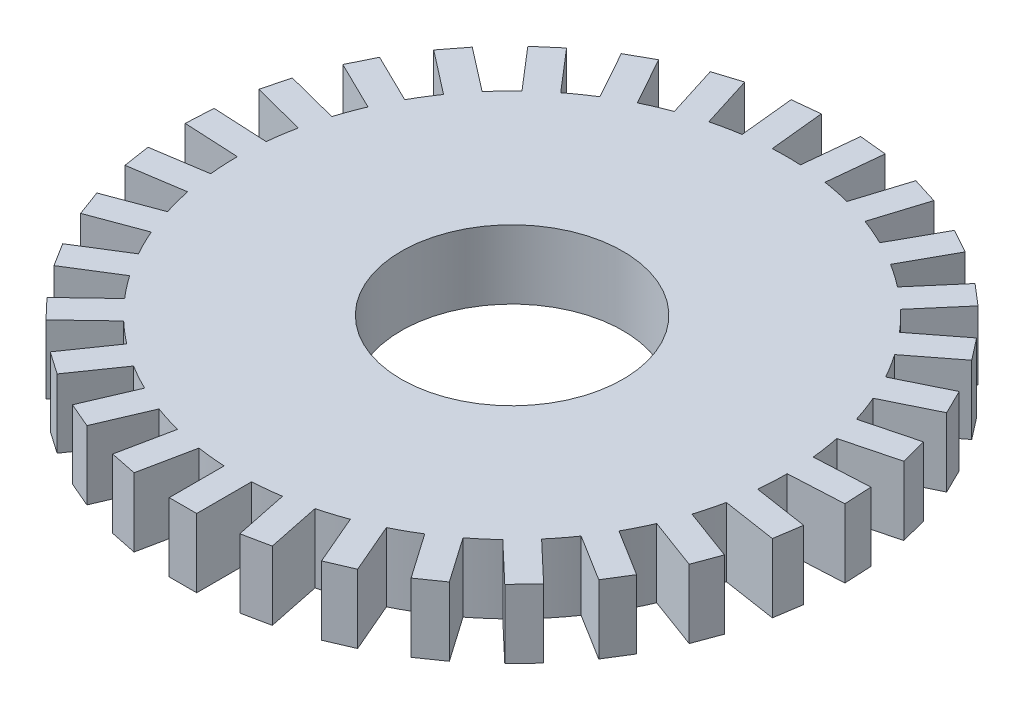
from build123d import *

# Parameters (mm, degrees)
BOSS_EXTRUDE4_DEPTH = 0.635
SKETCH2_R           = 1.00000054
CUT_EXTRUDE1_DEPTH  = 0.635
SKETCH3_R           = 1.025
CUT_EXTRUDE2_DEPTH  = 10


with BuildPart() as part:
    # Sketch1 → Boss-Extrude4 (new body)
    with BuildSketch(Plane(origin=(0, 0, 0), x_dir=(1, 0, 0), z_dir=(0, 1, 0))):
        with BuildLine():
            ThreePointArc((-0.384566693, 2.510718714), (-0.512856006, 2.487685414), (-0.63979484, 2.458101414))
            Line((-0.63979484, 2.458101414), (-0.882098552, 2.381911448))
            ThreePointArc((-0.882098552, 2.381911448), (-1.003125205, 2.333525192), (-1.121510378, 2.27899418))
            ThreePointArc((-1.121510378, 2.27899418), (-1.234057322, 2.220068135), (-1.343517192, 2.155588447))
            ThreePointArc((-1.343517192, 2.155588447), (-1.452326341, 2.083830175), (-1.557311151, 2.006584655))
            ThreePointArc((-1.557311151, 2.006584655), (-1.655692526, 1.926209297), (-1.749932081, 1.841015403))
            ThreePointArc((-1.749932081, 1.841015403), (-1.842069066, 1.748822906), (-1.929355422, 1.65202532))
            ThreePointArc((-1.929355422, 1.65202532), (-2.009543484, 1.553491225), (-2.084704544, 1.451070971))
            ThreePointArc((-2.084704544, 1.451070971), (-2.156397267, 1.342218621), (-2.222411655, 1.229831873))
            ThreePointArc((-2.222411655, 1.229831873), (-2.281123495, 1.117173039), (-2.334128959, 1.001719524))
            ThreePointArc((-2.334128959, 1.001719524), (-2.38244231, 0.880663749), (-2.424482094, 0.757288965))
            ThreePointArc((-2.424482094, 0.757288965), (-2.459314043, 0.635117657), (-2.487993859, 0.511357561))
            ThreePointArc((-2.487993859, 0.511357561), (-2.510949886, 0.383054399), (-2.527293951, 0.253742558))
            ThreePointArc((-2.527293951, 0.253742558), (-2.536819984, 0.127060484), (-2.539999999, 6.056e-05))
            ThreePointArc((-2.539999999, 6.056e-05), (-2.536658877, -0.130237243), (-2.526638097, -0.260192099))
            ThreePointArc((-2.526638097, -0.260192099), (-2.510468218, -0.38619856), (-2.488018241, -0.511238921))
            ThreePointArc((-2.488018241, -0.511238921), (-2.458516757, -0.638196957), (-2.422541382, -0.763474461))
            ThreePointArc((-2.422541382, -0.763474461), (-2.381337587, -0.88364659), (-2.334176723, -1.00160822))
            ThreePointArc((-2.334176723, -1.00160822), (-2.279722671, -1.120028813), (-2.219265538, -1.235500089))
            ThreePointArc((-2.219265538, -1.235500089), (-2.154714716, -1.344918024), (-2.084773736, -1.450971561))
            ThreePointArc((-2.084773736, -1.450971561), (-2.007596472, -1.556006557), (-1.925132703, -1.656944198))
            ThreePointArc((-1.925132703, -1.656944198), (-1.839877571, -1.751128357), (-1.750019867, -1.840931955))
            ThreePointArc((-1.750019867, -1.840931955), (-1.653279037, -1.92828121), (-1.552184709, -2.010552817))
            ThreePointArc((-1.552184709, -2.010552817), (-1.449715623, -2.085647289), (-1.34361998, -2.155524379))
            ThreePointArc((-1.34361998, -2.155524379), (-1.231276164, -2.221611804), (-1.11569009, -2.281849168))
            ThreePointArc((-1.11569009, -2.281849168), (-1.000202146, -2.334779576), (-0.882212132, -2.381869382))
            ThreePointArc((-0.882212132, -2.381869382), (-0.7588647, -2.42398935), (-0.633518988, -2.459726345))
            ThreePointArc((-0.633518988, -2.459726345), (-0.509740276, -2.488325712), (-0.384686416, -2.510700373))
            ThreePointArc((-0.384686416, -2.510700373), (-0.255385227, -2.527128486), (-0.125411544, -2.536902037))
            ThreePointArc((-0.125411544, -2.536902037), (0.001590421, -2.539999502), (0.128588407, -2.536742995))
            ThreePointArc((0.128588407, -2.536742995), (0.258549748, -2.526806686), (0.387830264, -2.510216661))
            ThreePointArc((0.387830264, -2.510216661), (0.512856006, -2.487685414), (0.636598805, -2.458931061))
            ThreePointArc((0.636598805, -2.458931061), (0.761899666, -2.423037123), (0.885194254, -2.380762721))
            ThreePointArc((0.885194254, -2.380762721), (1.003125205, -2.333525192), (1.118546774, -2.2804502))
            ThreePointArc((1.118546774, -2.2804502), (1.234057322, -2.220068135), (1.346318288, -2.153840074))
            ThreePointArc((1.346318288, -2.153840074), (1.452326341, -2.083830175), (1.554701306, -2.00860744))
            ThreePointArc((1.554701306, -2.00860744), (1.655692526, -1.926209297), (1.752323893, -1.838738963))
            ThreePointArc((1.752323893, -1.838738963), (1.842069066, -1.748822906), (1.927206184, -1.654532056))
            ThreePointArc((1.927206184, -1.654532056), (2.009543484, -1.553491225), (2.086589152, -1.448359662))
            ThreePointArc((2.086589152, -1.448359662), (2.156397267, -1.342218621), (2.220811015, -1.232719935))
            ThreePointArc((2.220811015, -1.232719935), (2.281123495, -1.117173039), (2.335429206, -0.998684346))
            ThreePointArc((2.335429206, -0.998684346), (2.38244231, -0.880663749), (2.423495581, -0.760440115))
            ThreePointArc((2.423495581, -0.760440115), (2.459314043, -0.635117657), (2.488656514, -0.508122776))
            ThreePointArc((2.488656514, -0.508122776), (2.510949886, -0.383054399), (2.526961954, -0.257027787))
            ThreePointArc((2.526961954, -0.257027787), (2.536738394, -0.12867913), (2.54, 0))
            ThreePointArc((2.54, 0), (2.539999483, 0.001620701), (2.539997932, 0.003241401))
            ThreePointArc((2.539997932, 0.003241401), (2.536658877, 0.130237243), (2.526974207, 0.256907289))
            ThreePointArc((2.526974207, 0.256907289), (2.510468218, 0.38619856), (2.487351536, 0.514472874))
            ThreePointArc((2.487351536, 0.514472874), (2.458516757, 0.638196957), (2.42353184, 0.76032455))
            ThreePointArc((2.42353184, 0.76032455), (2.381337587, 0.88364659), (2.332872675, 1.004641767))
            ThreePointArc((2.332872675, 1.004641767), (2.279722671, 1.120028813), (2.220869794, 1.232614034))
            ThreePointArc((2.220869794, 1.232614034), (2.154714716, 1.344918024), (2.082885734, 1.453680508))
            ThreePointArc((2.082885734, 1.453680508), (2.007596472, 1.556006557), (1.927285078, 1.654440155))
            ThreePointArc((1.927285078, 1.654440155), (1.839877571, 1.751128357), (1.747625206, 1.843205398))
            ThreePointArc((1.747625206, 1.843205398), (1.653279037, 1.92828121), (1.554797085, 2.008533302))
            ThreePointArc((1.554797085, 2.008533302), (1.449715623, 2.085647289), (1.340816696, 2.157269243))
            ThreePointArc((1.340816696, 2.157269243), (1.231276164, 2.221611804), (1.118655516, 2.28039686))
            ThreePointArc((1.118655516, 2.28039686), (1.000202146, 2.334779576), (0.879114993, 2.383014232))
            ThreePointArc((0.879114993, 2.383014232), (0.7588647, 2.42398935), (0.636716058, 2.458900702))
            ThreePointArc((0.636716058, 2.458900702), (0.509740276, 2.488325712), (0.38142222, 2.511198338))
            ThreePointArc((0.38142222, 2.511198338), (0.255385227, 2.527128486), (0.128709371, 2.53673686))
            ThreePointArc((0.128709371, 2.53673686), (-0.001590421, 2.539999502), (-0.131886025, 2.536573688))
            ThreePointArc((-0.131886025, 2.536573688), (-0.258549748, 2.526806686), (-0.384566693, 2.510718714))
        make_face()
        with BuildLine():
            Line((-0.882098552, 2.381911448), (-0.63979484, 2.458101414))
            ThreePointArc((-0.63979484, 2.458101414), (-0.761899666, 2.423037123), (-0.882098552, 2.381911448))
        make_face()
        with BuildLine():
            ThreePointArc((-0.882098552, 2.381911448), (-0.761899666, 2.423037123), (-0.63979484, 2.458101414))
            Line((-0.63979484, 2.458101414), (-0.792174773, 2.942708839))
            Line((-0.792174773, 2.942708839), (-1.034478485, 2.866518872))
            Line((-1.034478485, 2.866518872), (-0.882098552, 2.381911448))
        make_face()
        with BuildLine():
            Line((-0.436276643, 3.016080051), (-0.384566693, 2.510718714))
            ThreePointArc((-0.384566693, 2.510718714), (-0.258549748, 2.526806686), (-0.131886025, 2.536573688))
            Line((-0.131886025, 2.536573688), (-0.183595974, 3.041935026))
            Line((-0.183595974, 3.041935026), (-0.436276643, 3.016080051))
        make_face()
        with BuildLine():
            Line((0.179786416, 3.042162557), (0.128709371, 2.53673686))
            ThreePointArc((0.128709371, 2.53673686), (0.255385227, 2.527128486), (0.38142222, 2.511198338))
            Line((0.38142222, 2.511198338), (0.432499265, 3.016624035))
            Line((0.432499265, 3.016624035), (0.179786416, 3.042162557))
        make_face()
        with BuildLine():
            Line((0.788488998, 2.943698572), (0.636716058, 2.458900702))
            ThreePointArc((0.636716058, 2.458900702), (0.7588647, 2.42398935), (0.879114993, 2.383014232))
            Line((0.879114993, 2.383014232), (1.030887933, 2.867812102))
            Line((1.030887933, 2.867812102), (0.788488998, 2.943698572))
        make_face()
        with BuildLine():
            Line((1.364910748, 2.72471922), (1.118655516, 2.28039686))
            ThreePointArc((1.118655516, 2.28039686), (1.231276164, 2.221611804), (1.340816696, 2.157269243))
            Line((1.340816696, 2.157269243), (1.587071929, 2.601591604))
            Line((1.587071929, 2.601591604), (1.364910748, 2.72471922))
        make_face()
        with BuildLine():
            Line((1.885452892, 2.394189544), (1.554797085, 2.008533302))
            ThreePointArc((1.554797085, 2.008533302), (1.653279037, 1.92828121), (1.747625206, 1.843205398))
            Line((1.747625206, 1.843205398), (2.078281013, 2.22886164))
            Line((2.078281013, 2.22886164), (1.885452892, 2.394189544))
        make_face()
        with BuildLine():
            Line((2.328804373, 1.965641467), (1.927285078, 1.654440155))
            ThreePointArc((1.927285078, 1.654440155), (2.007596472, 1.556006557), (2.082885734, 1.453680508))
            Line((2.082885734, 1.453680508), (2.484405028, 1.76488182))
            Line((2.484405028, 1.76488182), (2.328804373, 1.965641467))
        make_face()
        with BuildLine():
            Line((2.676814329, 1.456619797), (2.220869794, 1.232614034))
            ThreePointArc((2.220869794, 1.232614034), (2.279722671, 1.120028813), (2.332872675, 1.004641767))
            Line((2.332872675, 1.004641767), (2.78881721, 1.22864753))
            Line((2.78881721, 1.22864753), (2.676814329, 1.456619797))
        make_face()
        with BuildLine():
            Line((2.915235191, 0.887963941), (2.42353184, 0.76032455))
            ThreePointArc((2.42353184, 0.76032455), (2.458516757, 0.638196957), (2.487351536, 0.514472874))
            Line((2.487351536, 0.514472874), (2.979054887, 0.642112265))
            Line((2.979054887, 0.642112265), (2.915235191, 0.887963941))
        make_face()
        with BuildLine():
            Line((3.034305983, 0.282954737), (2.526974207, 0.256907289))
            ThreePointArc((2.526974207, 0.256907289), (2.536658877, 0.130237243), (2.539997932, 0.003241401))
            Line((2.539997932, 0.003241401), (3.047329707, 0.029288849))
            Line((3.047329707, 0.029288849), (3.034305983, 0.282954737))
        make_face()
        with BuildLine():
            Line((3.029151931, -0.333638667), (2.526961954, -0.257027787))
            ThreePointArc((2.526961954, -0.257027787), (2.510949886, -0.383054399), (2.488656514, -0.508122776))
            Line((2.488656514, -0.508122776), (2.990846491, -0.584733655))
            Line((2.990846491, -0.584733655), (3.029151931, -0.333638667))
        make_face()
        with BuildLine():
            Line((2.899984043, -0.936572864), (2.423495581, -0.760440115))
            ThreePointArc((2.423495581, -0.760440115), (2.38244231, -0.880663749), (2.335429206, -0.998684346))
            Line((2.335429206, -0.998684346), (2.811917668, -1.174817096))
            Line((2.811917668, -1.174817096), (2.899984043, -0.936572864))
        make_face()
        with BuildLine():
            Line((2.652090468, -1.501163659), (2.220811015, -1.232719935))
            ThreePointArc((2.220811015, -1.232719935), (2.156397267, -1.342218621), (2.086589152, -1.448359662))
            Line((2.086589152, -1.448359662), (2.517868606, -1.716803386))
            Line((2.517868606, -1.716803386), (2.652090468, -1.501163659))
        make_face()
        with BuildLine():
            Line((2.295619997, -2.004296637), (1.927206184, -1.654532056))
            ThreePointArc((1.927206184, -1.654532056), (1.842069066, -1.748822906), (1.752323893, -1.838738963))
            Line((1.752323893, -1.838738963), (2.120737707, -2.188503544))
            Line((2.120737707, -2.188503544), (2.295619997, -2.004296637))
        make_face()
        with BuildLine():
            Line((1.845166574, -2.425373475), (1.554701306, -2.00860744))
            ThreePointArc((1.554701306, -2.00860744), (1.452326341, -2.083830175), (1.346318288, -2.153840074))
            Line((1.346318288, -2.153840074), (1.636783557, -2.570606109))
            Line((1.636783557, -2.570606109), (1.845166574, -2.425373475))
        make_face()
        with BuildLine():
            Line((1.319171815, -2.747155239), (1.118546774, -2.2804502))
            ThreePointArc((1.118546774, -2.2804502), (1.003125205, -2.333525192), (0.885194254, -2.380762721))
            Line((0.885194254, -2.380762721), (1.085819296, -2.847467759))
            Line((1.085819296, -2.847467759), (1.319171815, -2.747155239))
        make_face()
        with BuildLine():
            ThreePointArc((0.636598805, -2.458931061), (0.512856006, -2.487685414), (0.387830264, -2.510216661))
            Line((0.387830264, -2.510216661), (0.490401465, -3.007753744))
            Line((0.490401465, -3.007753744), (0.739170006, -2.956468143))
            Line((0.739170006, -2.956468143), (0.636598805, -2.458931061))
        make_face()
        with BuildLine():
            ThreePointArc((0.128588407, -2.536742995), (0.001590421, -2.539999502), (-0.125411544, -2.536902037))
            Line((-0.125411544, -2.536902037), (-0.125093459, -3.044901937))
            Line((-0.125093459, -3.044901937), (0.128906491, -3.044742895))
            Line((0.128906491, -3.044742895), (0.128588407, -2.536742995))
        make_face()
        with BuildLine():
            ThreePointArc((-0.384686416, -2.510700373), (-0.509740276, -2.488325712), (-0.633518988, -2.459726345))
            Line((-0.633518988, -2.459726345), (-0.735467043, -2.957391488))
            Line((-0.735467043, -2.957391488), (-0.486634472, -3.008365515))
            Line((-0.486634472, -3.008365515), (-0.384686416, -2.510700373))
        make_face()
        with BuildLine():
            ThreePointArc((-0.882212132, -2.381869382), (-1.000202146, -2.334779576), (-1.11569009, -2.281849168))
            Line((-1.11569009, -2.281849168), (-1.315730519, -2.748805083))
            Line((-1.315730519, -2.748805083), (-1.082252561, -2.848825297))
            Line((-1.082252561, -2.848825297), (-0.882212132, -2.381869382))
        make_face()
        with BuildLine():
            ThreePointArc((-1.34361998, -2.155524379), (-1.449715623, -2.085647289), (-1.552184709, -2.010552817))
            Line((-1.552184709, -2.010552817), (-1.842127833, -2.427682275))
            Line((-1.842127833, -2.427682275), (-1.633563104, -2.572653837))
            Line((-1.633563104, -2.572653837), (-1.34361998, -2.155524379))
        make_face()
        with BuildLine():
            ThreePointArc((-1.750019867, -1.840931955), (-1.839877571, -1.751128357), (-1.925132703, -1.656944198))
            Line((-1.925132703, -1.656944198), (-2.293108217, -2.00716987))
            Line((-2.293108217, -2.00716987), (-2.117995382, -2.191157627))
            Line((-2.117995382, -2.191157627), (-1.750019867, -1.840931955))
        make_face()
        with BuildLine():
            ThreePointArc((-2.084773736, -1.450971561), (-2.154714716, -1.344918024), (-2.219265538, -1.235500089))
            Line((-2.219265538, -1.235500089), (-2.650208482, -1.504483694))
            Line((-2.650208482, -1.504483694), (-2.515716679, -1.719955165))
            Line((-2.515716679, -1.719955165), (-2.084773736, -1.450971561))
        make_face()
        with BuildLine():
            ThreePointArc((-2.334176723, -1.00160822), (-2.381337587, -0.88364659), (-2.422541382, -0.763474461))
            Line((-2.422541382, -0.763474461), (-2.898808899, -0.940203779))
            Line((-2.898808899, -0.940203779), (-2.81044424, -1.178337538))
            Line((-2.81044424, -1.178337538), (-2.334176723, -1.00160822))
        make_face()
        with BuildLine():
            ThreePointArc((-2.488018241, -0.511238921), (-2.510468218, -0.38619856), (-2.526638097, -0.260192099))
            Line((-2.526638097, -0.260192099), (-3.02873174, -0.337431811))
            Line((-3.02873174, -0.337431811), (-2.990111884, -0.588478633))
            Line((-2.990111884, -0.588478633), (-2.488018241, -0.511238921))
        make_face()
        with BuildLine():
            ThreePointArc((-2.539999999, 6.056e-05), (-2.536819984, 0.127060484), (-2.527293951, 0.253742558))
            Line((-2.527293951, 0.253742558), (-3.034657948, 0.279154655))
            Line((-3.034657948, 0.279154655), (-3.047363996, 0.025472657))
            Line((-3.047363996, 0.025472657), (-2.539999999, 6.056e-05))
        make_face()
        with BuildLine():
            ThreePointArc((-2.487993859, 0.511357561), (-2.459314043, 0.635117657), (-2.424482094, 0.757288965))
            Line((-2.424482094, 0.757288965), (-2.916344902, 0.884312497))
            Line((-2.916344902, 0.884312497), (-2.979856668, 0.638381093))
            Line((-2.979856668, 0.638381093), (-2.487993859, 0.511357561))
        make_face()
        with BuildLine():
            ThreePointArc((-2.334128959, 1.001719524), (-2.281123495, 1.117173039), (-2.222411655, 1.229831873))
            Line((-2.222411655, 1.229831873), (-2.678636354, 1.453266481))
            Line((-2.678636354, 1.453266481), (-2.790353658, 1.225154131))
            Line((-2.790353658, 1.225154131), (-2.334128959, 1.001719524))
        make_face()
        with BuildLine():
            ThreePointArc((-2.084704544, 1.451070971), (-2.009543484, 1.553491225), (-1.929355422, 1.65202532))
            Line((-1.929355422, 1.65202532), (-2.331264118, 1.962723565))
            Line((-2.331264118, 1.962723565), (-2.486613241, 1.761769216))
            Line((-2.486613241, 1.761769216), (-2.084704544, 1.451070971))
        make_face()
        with BuildLine():
            ThreePointArc((-1.749932081, 1.841015403), (-1.655692526, 1.926209297), (-1.557311151, 2.006584655))
            Line((-1.557311151, 2.006584655), (-1.888449656, 2.391826515))
            Line((-1.888449656, 2.391826515), (-2.081070586, 2.226257262))
            Line((-2.081070586, 2.226257262), (-1.749932081, 1.841015403))
        make_face()
        with BuildLine():
            ThreePointArc((-1.343517192, 2.155588447), (-1.234057322, 2.220068135), (-1.121510378, 2.27899418))
            Line((-1.121510378, 2.27899418), (-1.368321843, 2.723007807))
            Line((-1.368321843, 2.723007807), (-1.590328656, 2.599602074))
            Line((-1.590328656, 2.599602074), (-1.343517192, 2.155588447))
        make_face()
    extrude(amount=BOSS_EXTRUDE4_DEPTH)

    # Sketch2 → Cut-Extrude1 (cut)
    with BuildSketch(Plane(origin=(0, 0.635, 0), x_dir=(1, 0, 0), z_dir=(0, 1, 0))):
        with Locations(Location((0, 0, 0), (0, 0, 270))):  # turned: the seam where the file's is
            Circle(SKETCH2_R)
    extrude(amount=-CUT_EXTRUDE1_DEPTH, mode=Mode.SUBTRACT)

    # Sketch3 → Cut-Extrude2 (cut)
    with BuildSketch(Plane(origin=(0, 0.635, 0), x_dir=(1, 0, 0), z_dir=(0, 1, 0))):
        with Locations(Location((0, 0, 0), (0, 0, 270))):  # turned: the seam where the file's is
            Circle(SKETCH3_R)
    extrude(amount=-CUT_EXTRUDE2_DEPTH, mode=Mode.SUBTRACT)


solid = part.part
